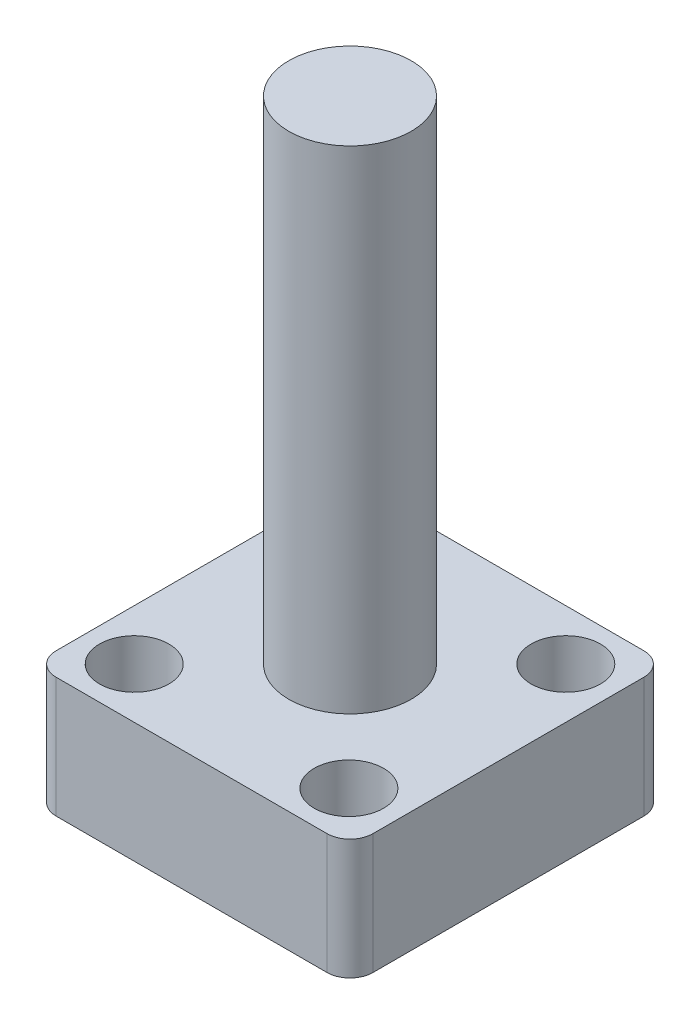
from build123d import *

# Parameters (mm, degrees)
SKETCH1_W           = 52.578
SKETCH1_H           = 52.578
EXTRUDE1_DEPTH      = 19.9644
EXTRUDE2_START      = -19.9644
SKETCH2_R           = 2.667
EXTRUDE2_DEPTH      = 5.7658
EXTRUDE4_START      = -19.9644
SKETCH6_R           = 5.75437
EXTRUDE4_DEPTH      = 14.1986
FILLET2_R           = 3.81
SKETCH7_R           = 10.16
BOSS_EXTRUDE1_DEPTH = 101.6


with BuildPart() as part:
    # Sketch1 → Extrude1 (new body)
    with BuildSketch(Plane(origin=(0, 0, 0), x_dir=(1, 0, 0), z_dir=(0, 1, 0))):
        Rectangle(SKETCH1_W, SKETCH1_H)
    extrude(amount=EXTRUDE1_DEPTH)

    # Sketch2 → Extrude2 (cut)
    with BuildSketch(Plane(origin=(0, 19.9644, 0), x_dir=(1, 0, 0), z_dir=(0, 1, 0)).offset(EXTRUDE2_START)):
        with Locations((-17.907, 17.907)):
            Circle(SKETCH2_R)
        with Locations((-17.907, -17.907)):
            Circle(SKETCH2_R)
        with Locations((18.02131475, -17.695628339)):
            Circle(SKETCH2_R)
        with Locations((17.907, 17.907)):
            Circle(SKETCH2_R)
    extrude(amount=EXTRUDE2_DEPTH, mode=Mode.SUBTRACT)

    # Sketch6 → Extrude4 (cut)
    with BuildSketch(Plane.XZ.offset(EXTRUDE4_START)):
        with Locations((-17.907, -17.907)):
            Circle(SKETCH6_R)
        with Locations((-17.907, 17.907)):
            Circle(SKETCH6_R)
        with Locations((17.772836554, 17.95632809)):
            Circle(SKETCH6_R)
        with Locations((17.907, -17.907)):
            Circle(SKETCH6_R)
    extrude(amount=EXTRUDE4_DEPTH, mode=Mode.SUBTRACT)

    # Fillet2
    fillet2_edges = [part.edges().sort_by_distance(p)[0] for p in [
        (-26.289, 9.9822, -26.289),
        (26.289, 9.9822, -26.289),
        (26.289, 9.9822, 26.289),
        (-26.289, 9.9822, 26.289),
    ]]
    fillet(fillet2_edges, radius=FILLET2_R)

    # Sketch7 → Boss-Extrude1 (add)
    with BuildSketch(Plane(origin=(0, 0, 0), x_dir=(1, 0, 0), z_dir=(0, 1, 0))):
        Circle(SKETCH7_R)
    extrude(amount=BOSS_EXTRUDE1_DEPTH)


solid = part.part
